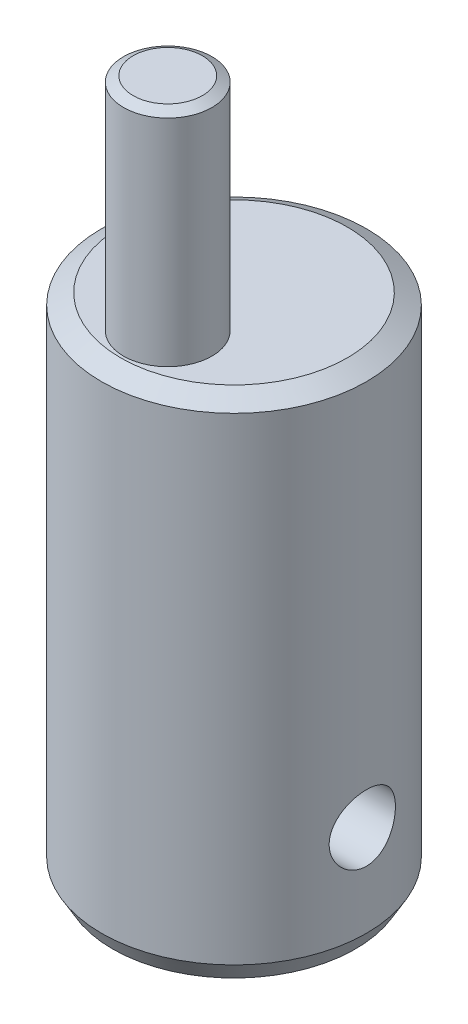
from build123d import *

# Parameters (mm, degrees)
SKETCH1_R               = 6
BOSS_EXTRUDE1_DEPTH     = 23
SKETCH2_R               = 2
BOSS_EXTRUDE2_DEPTH     = 10
SKETCH3_R               = 1.5
CUT_EXTRUDE1_DEPTH      = 7
CUT_EXTRUDE1_DEPTH_BACK = 7
CHAMFER1_SIZE           = 0.25
CHAMFER1_SIZE2          = 0.433012702
CHAMFER2_SIZE           = 0.5
CHAMFER2_SIZE2          = 0.866025404
CHAMFER2_PART_2_SIZE    = 0.5
CHAMFER2_PART_2_SIZE2   = 0.866025404


with BuildPart() as part:
    # Sketch1 → Boss-Extrude1 (new body)
    with BuildSketch(Plane(origin=(0, 0, 0), x_dir=(1, 0, 0), z_dir=(0, 1, 0))):
        Circle(SKETCH1_R)
    extrude(amount=BOSS_EXTRUDE1_DEPTH)

    # Sketch2 → Boss-Extrude2 (add)
    with BuildSketch(Plane(origin=(0, 23, 0), x_dir=(1, 0, 0), z_dir=(0, 1, 0))):
        with Locations((0, -3)):
            Circle(SKETCH2_R)
    extrude(amount=BOSS_EXTRUDE2_DEPTH)

    # Sketch3 → Cut-Extrude1 (cut, two sides)
    with BuildSketch(Plane(origin=(0, 0, 0), x_dir=(0, 0, -1), z_dir=(1, 0, 0))) as cut_extrude1_sk:
        with Locations((0, 5)):
            Circle(SKETCH3_R)
    extrude(amount=CUT_EXTRUDE1_DEPTH, mode=Mode.SUBTRACT)
    extrude(cut_extrude1_sk.sketch, amount=-CUT_EXTRUDE1_DEPTH_BACK, mode=Mode.SUBTRACT)

    # Chamfer1
    chamfer1_edges = [part.edges().sort_by_distance(p)[0] for p in [
        (-2, 33, 3),
    ]]
    chamfer1_side = [part.faces().sort_by_distance(p)[0] for p in [
        (-2, 28, 3),
    ]]
    chamfer(chamfer1_edges, length=CHAMFER1_SIZE, length2=CHAMFER1_SIZE2, reference=chamfer1_side[0])

    # Chamfer2
    chamfer2_edges = [part.edges().sort_by_distance(p)[0] for p in [
        (-6, 0, 0),
    ]]
    chamfer2_side = [part.faces().sort_by_distance(p)[0] for p in [
        (0, 0, 0),
    ]]
    chamfer(chamfer2_edges, length=CHAMFER2_SIZE, length2=CHAMFER2_SIZE2, reference=chamfer2_side[0])

    # Chamfer2 part 2
    chamfer2_part_2_edges = [part.edges().sort_by_distance(p)[0] for p in [
        (-6, 23, 0),
    ]]
    chamfer2_part_2_side = [part.faces().sort_by_distance(p)[0] for p in [
        (-6, 11.5, 0),
    ]]
    chamfer(chamfer2_part_2_edges, length=CHAMFER2_PART_2_SIZE, length2=CHAMFER2_PART_2_SIZE2, reference=chamfer2_part_2_side[0])


solid = part.part
